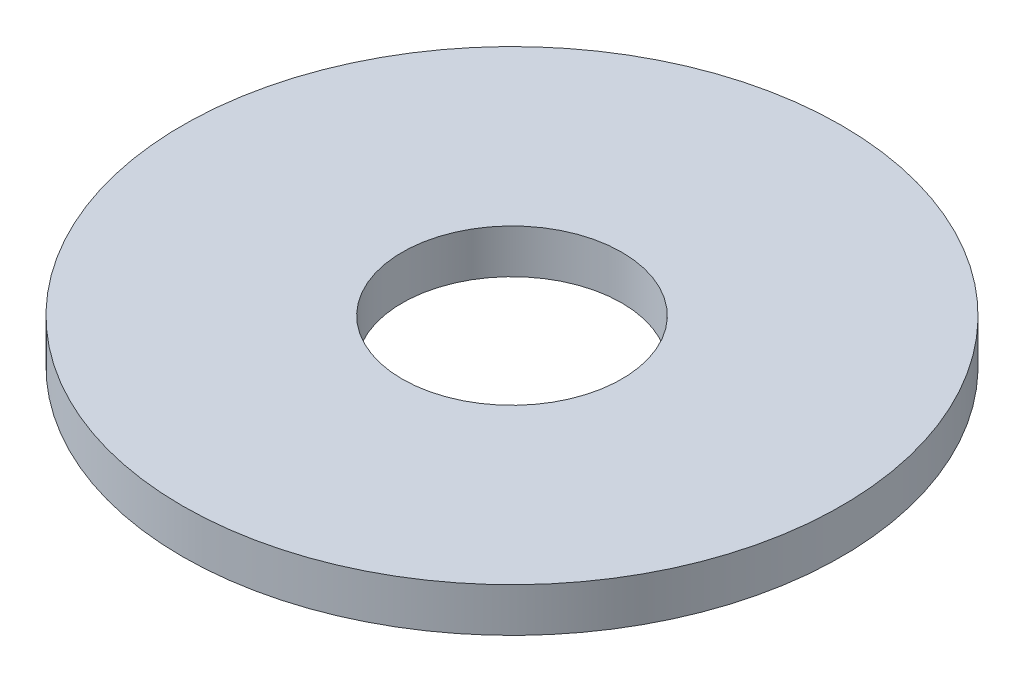
from build123d import *

# Parameters (mm, degrees)
SKETCH1_R           = 30
BOSS_EXTRUDE1_DEPTH = 4
SKETCH2_R           = 10
CUT_EXTRUDE1_DEPTH  = 10


with BuildPart() as part:
    # Sketch1 → Boss-Extrude1 (new body)
    with BuildSketch(Plane(origin=(0, 0, 0), x_dir=(1, 0, 0), z_dir=(0, 1, 0))):
        Circle(SKETCH1_R)
    extrude(amount=BOSS_EXTRUDE1_DEPTH)

    # Sketch2 → Cut-Extrude1 (cut)
    with BuildSketch(Plane(origin=(0, 4, 0), x_dir=(1, 0, 0), z_dir=(0, 1, 0))):
        Circle(SKETCH2_R)
    extrude(amount=-CUT_EXTRUDE1_DEPTH, mode=Mode.SUBTRACT)


solid = part.part
